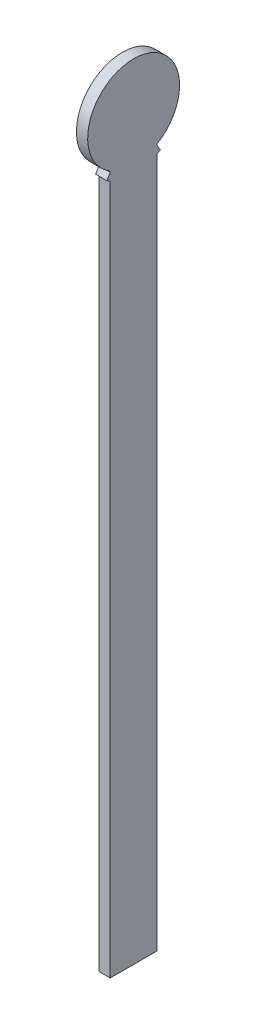
from build123d import *

# Parameters (mm, degrees)
BOSS_EXTRUDE1_DEPTH = 3


with BuildPart() as part:
    # Sketch1 → Boss-Extrude1 (new body, symmetric)
    with BuildSketch(Plane(origin=(0, 0, 0), x_dir=(0, 0, -1), z_dir=(1, 0, 0))):
        with BuildLine():
            ThreePointArc((12.5, 175.728692494), (0, 221.3), (-12.5, 175.728692494))
            Line((-12.5, 175.728692494), (-12.5, 175.149364905))
            Line((-12.5, 175.149364905), (-14.25, 172.118275992))
            ThreePointArc((-14.25, 172.118275992), (-13.38309417, 171.637671204), (-12.5, 171.18750305))
            Line((-12.5, 171.18750305), (-12.5, -196.8))
            Line((-12.5, -196.8), (12.5, -196.8))
            Line((12.5, -196.8), (12.5, 171.18750305))
            ThreePointArc((12.5, 171.18750305), (13.38309417, 171.637671204), (14.25, 172.118275992))
            Line((14.25, 172.118275992), (12.5, 175.149364905))
            Line((12.5, 175.149364905), (12.5, 175.728692494))
        make_face()
    extrude(amount=BOSS_EXTRUDE1_DEPTH, both=True)


solid = part.part
